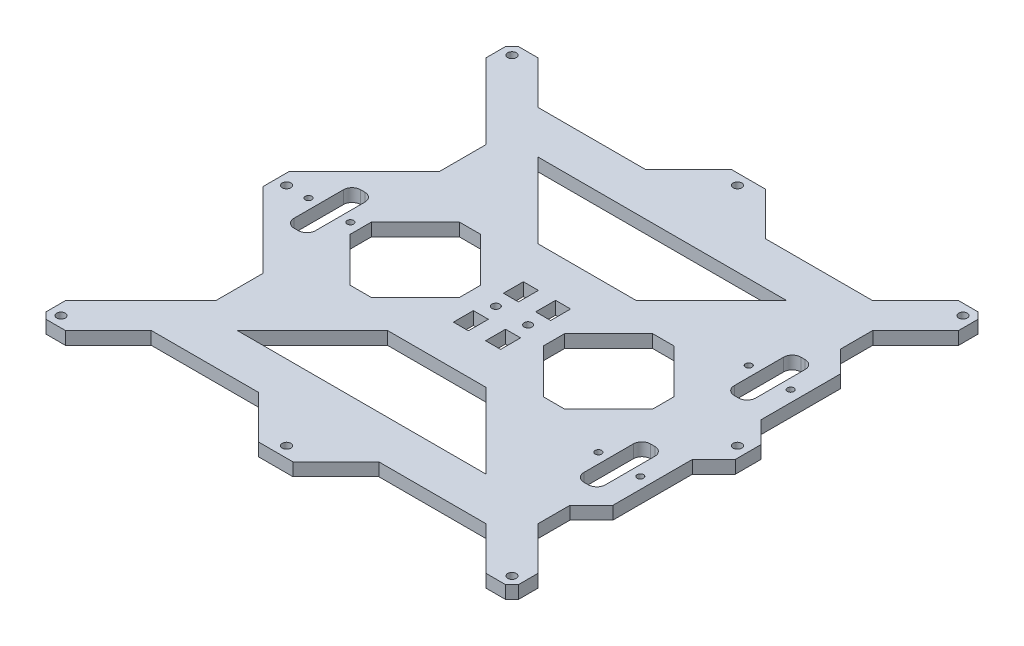
from build123d import *

# Parameters (mm, degrees)
BOSS_EXTRU_1_DEPTH      = 6
ENL_V_MAT_EXTRU_2_DEPTH = 6
CHANFREIN1_SIZE         = 3
ESQUISSE4_R             = 1.8
ESQUISSE4_W             = 7
ESQUISSE4_H             = 9.3
ENL_V_MAT_EXTRU_3_DEPTH = 6
CHANFREIN2_SIZE         = 7
BOSS_EXTRU_2_DEPTH      = 6
ESQUISSE11_R            = 2
ENL_V_MAT_EXTRU_6_DEPTH = 6
ESQUISSE12_R            = 1.5
ENL_V_MAT_EXTRU_7_DEPTH = 10


with BuildPart() as part:
    # Esquisse1 → Boss.-Extru.1 (new body)
    with BuildSketch(Plane(origin=(0, 0, 0), x_dir=(1, 0, 0), z_dir=(0, 1, 0))):
        Polygon((0, 0), (0, 110), (-8, 110), (-28, 90), (-78, 90), (-98, 110), (-110, 110), (-110, 98), (-75, 63), (-75, 41), (-110, 6), (-110, 0), align=None)
    extrude(amount=BOSS_EXTRU_1_DEPTH)

    # Esquisse3 → Enlèv. mat.-Extru.2 (cut)
    with BuildSketch(Plane(origin=(0, 0, 0), x_dir=(1, 0, 0), z_dir=(0, 1, 0))):
        Polygon((0, 70), (-58, 70), (-23, 35), (0, 35), align=None)
    extrude(amount=ENL_V_MAT_EXTRU_2_DEPTH, mode=Mode.SUBTRACT)

    # Chanfrein1
    chanfrein1_edges = [part.edges().sort_by_distance(p)[0] for p in [
        (-110, 3, -110),
    ]]
    chamfer(chanfrein1_edges, length=CHANFREIN1_SIZE)

    # Symétrie3: part across plane


with BuildPart() as part_1:
    add(part.part)
    add(part.part.mirror(Plane(origin=(-110, 6, 0), x_dir=(1, 0, 0), z_dir=(0, 0, -1))))

    # Esquisse4 → Enlèv. mat.-Extru.3 (cut)
    with BuildSketch(Plane(origin=(0, 6, 0), x_dir=(1, 0, 0), z_dir=(0, 1, 0))):
        with Locations((-7.5, 0)):
            Circle(ESQUISSE4_R)
        Polygon((-45, 30.405591591), (-14.594408409, 0), (-45, -30.405591591), (-75.405591591, 0), align=None)
        with Locations((-7.5, 11.65)):
            Rectangle(ESQUISSE4_W, ESQUISSE4_H)
        with Locations((-7.5, -11.65)):
            Rectangle(ESQUISSE4_W, ESQUISSE4_H)
    extrude(amount=-ENL_V_MAT_EXTRU_3_DEPTH, mode=Mode.SUBTRACT)

    # Chanfrein2
    chanfrein2_edges = [part_1.edges().sort_by_distance(p)[0] for p in [
        (-14.594408409, 3, 0),
        (-45, 3, 30.405591591),
        (-75.405591591, 3, 0),
        (-45, 3, -30.405591591),
    ]]
    chamfer(chanfrein2_edges, length=CHANFREIN2_SIZE)

    # Symétrie5: part across plane


with BuildPart() as part_2:
    add(part_1.part)
    add(part_1.part.mirror(Plane(origin=(0, 6, 0), x_dir=(0, 0, 1), z_dir=(-1, 0, 0))))

    # Esquisse8 → Boss.-Extru.2 (add)
    with BuildSketch(Plane(origin=(0, 6, 0), x_dir=(1, 0, 0), z_dir=(0, 1, 0))):
        Polygon((100, 16), (100, 53), (90, 63), (90, 78), (75, 63), (75, 41), align=None)
    boss_extru_2 = extrude(amount=-BOSS_EXTRU_2_DEPTH)

    # Esquisse11 → Enlèv. mat.-Extru.6 (cut)
    with BuildSketch(Plane(origin=(0, 6, 0), x_dir=(1, 0, 0), z_dir=(0, 1, 0))):
        with Locations((-105, 105)):
            Circle(ESQUISSE11_R)
        with Locations((0, 105)):
            Circle(ESQUISSE11_R)
        with Locations((105, 105)):
            Circle(ESQUISSE11_R)
        with Locations((105, 0)):
            Circle(ESQUISSE11_R)
        with Locations((105, -105)):
            Circle(ESQUISSE11_R)
        with Locations((0, -105)):
            Circle(ESQUISSE11_R)
        with Locations((-105, -105)):
            Circle(ESQUISSE11_R)
        with Locations((-105, 0)):
            Circle(ESQUISSE11_R)
    extrude(amount=-ENL_V_MAT_EXTRU_6_DEPTH, mode=Mode.SUBTRACT)

    # Symétrie6: Boss.-Extru.2 across plane
    add(boss_extru_2.mirror(Plane.XY))

    # Esquisse12 → Enlèv. mat.-Extru.7 (cut)
    with BuildSketch(Plane(origin=(0, 6, 0), x_dir=(1, 0, 0), z_dir=(0, 1, 0))):
        with Locations((-94.75, 0)):
            Circle(ESQUISSE12_R)
        with Locations((-75.25, 0)):
            Circle(ESQUISSE12_R)
        with Locations((75.25, 35)):
            Circle(ESQUISSE12_R)
        with Locations((94.75, 35)):
            Circle(ESQUISSE12_R)
        with Locations((75.25, -35)):
            Circle(ESQUISSE12_R)
        with Locations((94.75, -35)):
            Circle(ESQUISSE12_R)
        with BuildLine():
            Line((-86, 15.5), (-84, 15.5))
            ThreePointArc((-84, 15.5), (-81.171572875, 14.328427125), (-80, 11.5))
            Line((-80, 11.5), (-80, -11.5))
            ThreePointArc((-80, -11.5), (-81.171572875, -14.328427125), (-84, -15.5))
            Line((-84, -15.5), (-86, -15.5))
            ThreePointArc((-86, -15.5), (-88.828427125, -14.328427125), (-90, -11.5))
            Line((-90, -11.5), (-90, 11.5))
            ThreePointArc((-90, 11.5), (-88.828427125, 14.328427125), (-86, 15.5))
        make_face()
        with BuildLine():
            Line((84, 50.5), (86, 50.5))
            ThreePointArc((86, 50.5), (88.828427125, 49.328427125), (90, 46.5))
            Line((90, 46.5), (90, 23.5))
            ThreePointArc((90, 23.5), (88.828427125, 20.671572875), (86, 19.5))
            Line((86, 19.5), (84, 19.5))
            ThreePointArc((84, 19.5), (81.171572875, 20.671572875), (80, 23.5))
            Line((80, 23.5), (80, 46.5))
            ThreePointArc((80, 46.5), (81.171572875, 49.328427125), (84, 50.5))
        make_face()
        with BuildLine():
            Line((84, -19.5), (86, -19.5))
            ThreePointArc((86, -19.5), (88.828427125, -20.671572875), (90, -23.5))
            Line((90, -23.5), (90, -46.5))
            ThreePointArc((90, -46.5), (88.828427125, -49.328427125), (86, -50.5))
            Line((86, -50.5), (84, -50.5))
            ThreePointArc((84, -50.5), (81.171572875, -49.328427125), (80, -46.5))
            Line((80, -46.5), (80, -23.5))
            ThreePointArc((80, -23.5), (81.171572875, -20.671572875), (84, -19.5))
        make_face()
    extrude(amount=-ENL_V_MAT_EXTRU_7_DEPTH, mode=Mode.SUBTRACT)


solid = part_2.part
